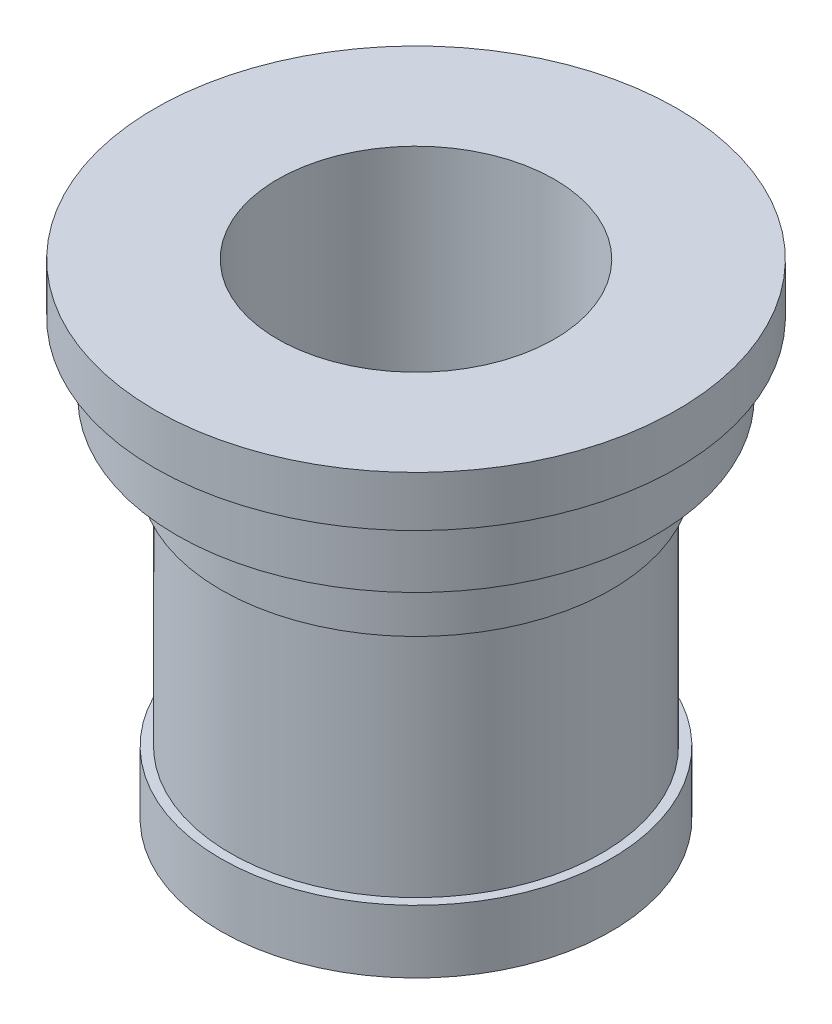
from build123d import *


with BuildPart() as part:
    # Sketch1 → Revolve1 (revolve)
    with BuildSketch(Plane.XY, mode=Mode.PRIVATE) as revolve1_sk:
        Polygon((22, 50.237882563), (22, -26.762117437), (31, -26.762117437), (31, -16.762117437), (29.5, -16.762117437), (29.5, 20.237882563), (31, 20.237882563), (31, 31.237882563), (38, 31.237882563), (38, 42.237882563), (41.5, 42.237882563), (41.5, 50.237882563), align=None)
    revolve(revolve1_sk.sketch.rotate(Axis((0, 0, 0), (0, 1, 0)), 90), axis=Axis((0, 0, 0), (0, 1, 0)))  # turned: the seam where the file's is


solid = part.part
